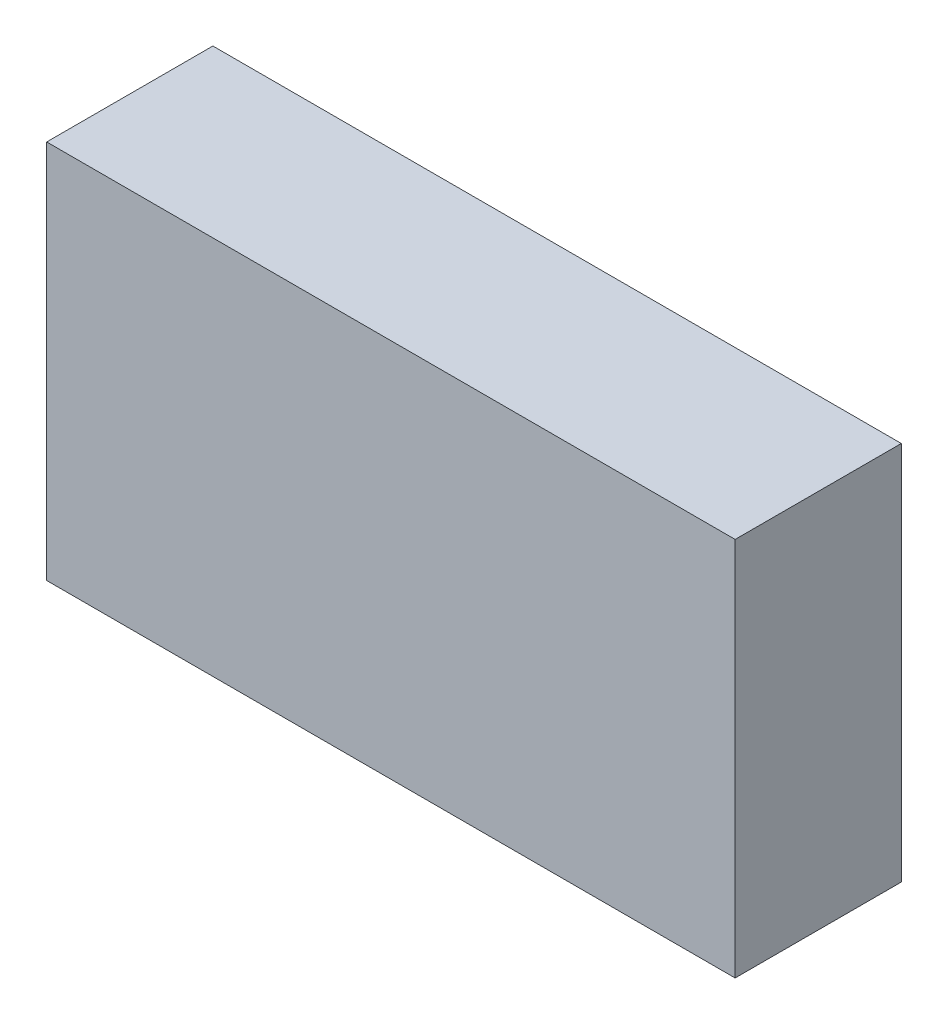
from build123d import *

# Parameters (mm, degrees)
SKETCH1_W           = 58
SKETCH1_H           = 32
BOSS_EXTRUDE1_DEPTH = 14


with BuildPart() as part:
    # Sketch1 → Boss-Extrude1 (new body)
    with BuildSketch(Plane.XY):
        Rectangle(SKETCH1_W, SKETCH1_H)
    extrude(amount=BOSS_EXTRUDE1_DEPTH)


solid = part.part
